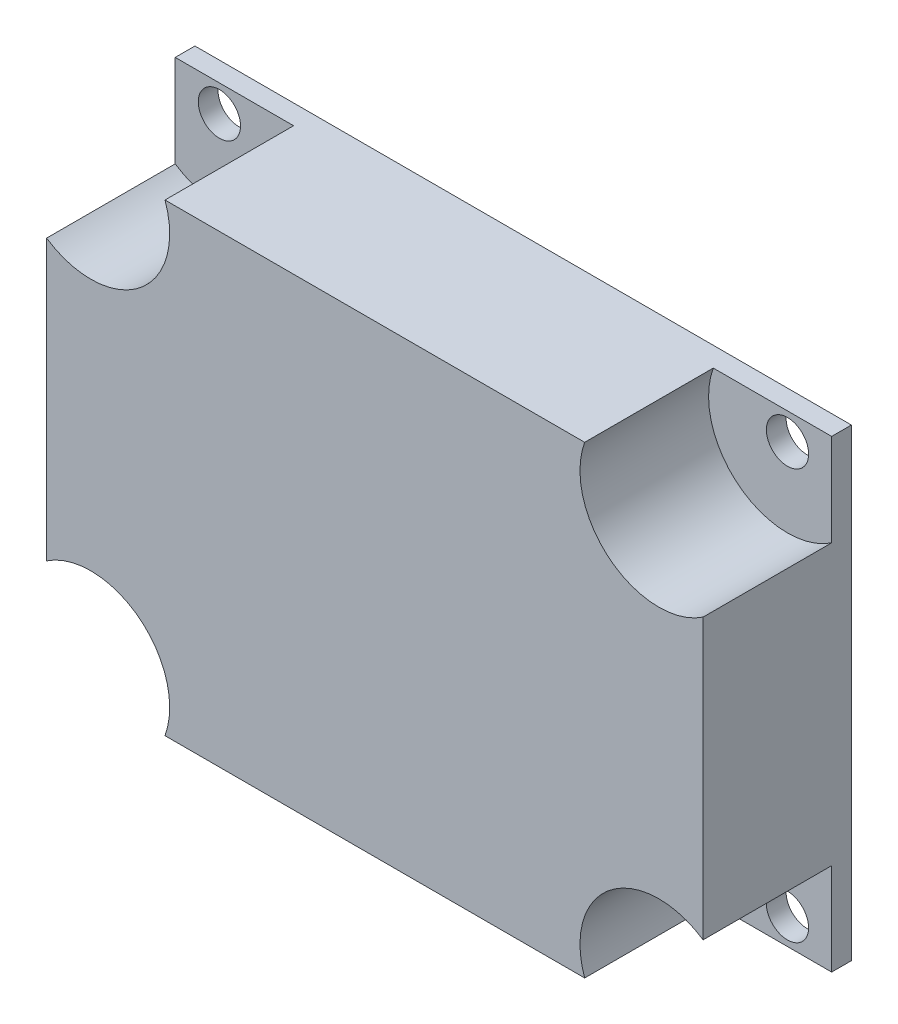
from build123d import *

# Parameters (mm, degrees)
SKETCH1_W                = 52.832
SKETCH1_H                = 37.338
BOSS_EXTRUDE1_DEPTH      = 11.938
M3_CLEARANCE_HOLE1_D     = 3.4
M3_CLEARANCE_HOLE1_DEPTH = 11.938
SKETCH4_R                = 6.35
CUT_EXTRUDE1_DEPTH       = 10.3505


with BuildPart() as part:
    # Sketch1 → Boss-Extrude1 (new body)
    with BuildSketch(Plane.XY):
        Rectangle(SKETCH1_W, SKETCH1_H)
    extrude(amount=BOSS_EXTRUDE1_DEPTH)

    # M3 Clearance Hole1
    with Locations(Plane.XY.offset(11.938)):
        with Locations((-22.86, 16.51), (22.86, -16.51), (22.86, 16.51), (-22.86, -16.51)):
            Hole(M3_CLEARANCE_HOLE1_D / 2, depth=M3_CLEARANCE_HOLE1_DEPTH)

    # Sketch4 → Cut-Extrude1 (cut)
    with BuildSketch(Plane.XY.offset(11.938)):
        with Locations((-22.86, 16.51)):
            Circle(SKETCH4_R)
        with Locations((-22.86, -16.51)):
            Circle(SKETCH4_R)
        with Locations((22.86, 16.51)):
            Circle(SKETCH4_R)
        with Locations((22.86, -16.51)):
            Circle(SKETCH4_R)
    extrude(amount=-CUT_EXTRUDE1_DEPTH, mode=Mode.SUBTRACT)


solid = part.part
